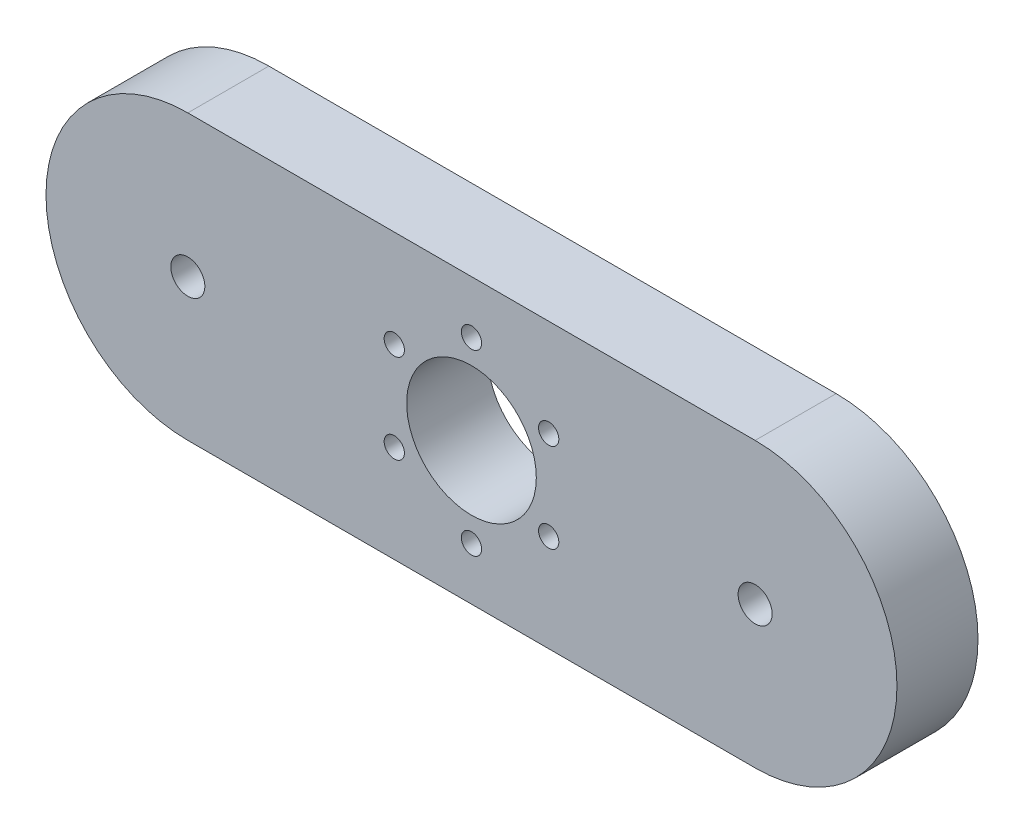
from build123d import *

# Parameters (mm, degrees)
IZIM1_R                     = 8
IZIM1_R_2                   = 2.1
IZIM1_R_3                   = 1.25
Y_KSEKLIK_EKSTR_ZYON1_DEPTH = 10


with BuildPart() as part:
    # Çizim1 → Yükseklik-Ekstrüzyon1 (new body)
    with BuildSketch(Plane.XY):
        with BuildLine():
            Line((-35, 17.5), (35, 17.5))
            ThreePointArc((35, 17.5), (52.5, 0), (35, -17.5))
            Line((35, -17.5), (-35, -17.5))
            ThreePointArc((-35, -17.5), (-52.5, 0), (-35, 17.5))
        make_face()
        Circle(IZIM1_R, mode=Mode.SUBTRACT)
        with Locations((-35, 0)):
            Circle(IZIM1_R_2, mode=Mode.SUBTRACT)
        with Locations((0, 11)):
            Circle(IZIM1_R_3, mode=Mode.SUBTRACT)
        with Locations((9.526279442, 5.5)):
            Circle(IZIM1_R_3, mode=Mode.SUBTRACT)
        with Locations((9.526279442, -5.5)):
            Circle(IZIM1_R_3, mode=Mode.SUBTRACT)
        with Locations((0, -11)):
            Circle(IZIM1_R_3, mode=Mode.SUBTRACT)
        with Locations((-9.526279442, -5.5)):
            Circle(IZIM1_R_3, mode=Mode.SUBTRACT)
        with Locations((-9.526279442, 5.5)):
            Circle(IZIM1_R_3, mode=Mode.SUBTRACT)
        with Locations((35, 0)):
            Circle(IZIM1_R_2, mode=Mode.SUBTRACT)
    extrude(amount=Y_KSEKLIK_EKSTR_ZYON1_DEPTH)


solid = part.part
